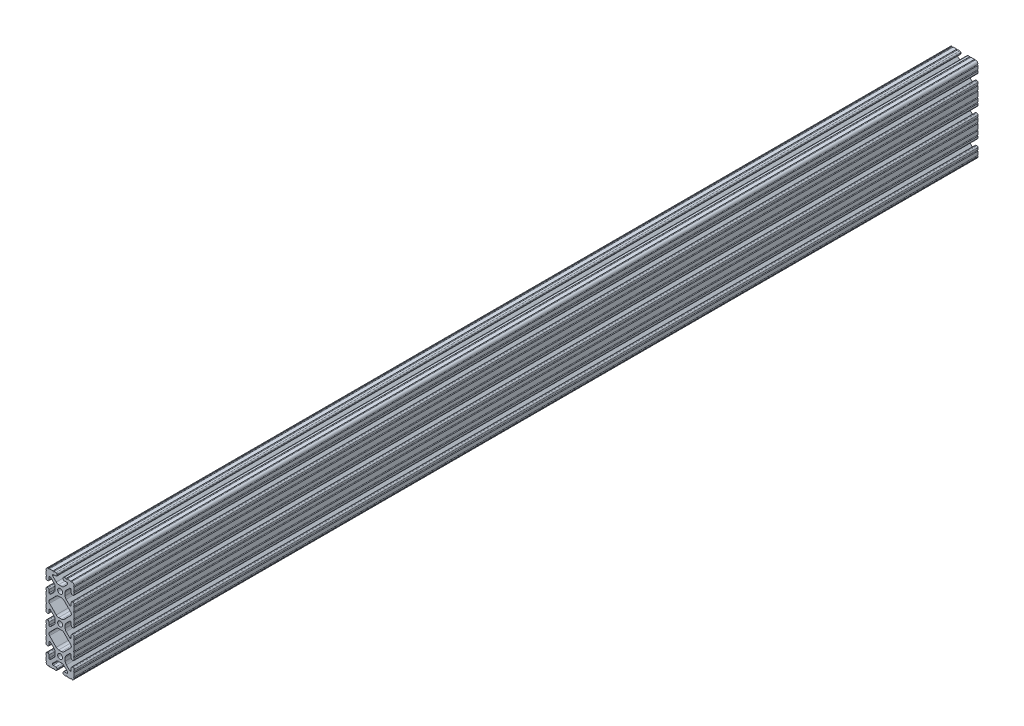
from build123d import *

# Parameters (mm, degrees)
SKETCH3_R                = 3.3274
BOSS_EXTRUDE1_DEPTH      = 609.6
BOSS_EXTRUDE1_DEPTH_BACK = 609.6


with BuildPart() as part:
    # Sketch3 → Boss-Extrude1 (new body, two sides)
    with BuildSketch(Plane.XY) as boss_extrude1_sk:
        with BuildLine():
            Line((-19.05, -5.6388), (-19.05, -8.023791585))
            ThreePointArc((-19.05, -8.023791585), (-18.288, -8.785791585), (-19.05, -9.547791585))
            Line((-19.05, -9.547791585), (-19.05, -13.984497194))
            ThreePointArc((-19.05, -13.984497194), (-18.288000009, -14.746497184), (-19.05, -15.508497175))
            Line((-19.05, -15.508497175), (-19.05, -22.30100558))
            ThreePointArc((-19.05, -22.30100558), (-18.288, -23.06300558), (-19.05, -23.82500558))
            Line((-19.05, -23.82500558), (-19.05, -28.653420271))
            ThreePointArc((-19.05, -28.653420271), (-18.288, -29.415420271), (-19.05, -30.177420271))
            Line((-19.05, -30.177420271), (-19.05, -32.4612))
            ThreePointArc((-19.05, -32.4612), (-18.588751759, -33.574751759), (-17.4752, -34.036))
            Line((-17.4752, -34.036), (-16.5608, -34.036))
            ThreePointArc((-16.5608, -34.036), (-15.447248241, -33.574751759), (-14.986, -32.4612))
            Line((-14.986, -32.4612), (-14.986, -28.7208616))
            ThreePointArc((-14.986, -28.7208616), (-14.725617928, -28.092243671), (-14.097, -27.8318616))
            Line((-14.097, -27.8318616), (-13.547779415, -27.8318616))
            ThreePointArc((-13.547779415, -27.8318616), (-13.207573844, -27.899532695), (-12.919161487, -28.092243671))
            Line((-12.919161487, -28.092243671), (-8.147584211, -32.863820948))
            ThreePointArc((-8.147584211, -32.863820948), (-7.117956996, -34.40476697), (-6.7564, -36.222436737))
            Line((-6.7564, -36.222436737), (-6.7564, -40.243886463))
            ThreePointArc((-6.7564, -40.243886463), (-7.222930328, -42.088789954), (-8.376184211, -43.602502252))
            Line((-8.376184211, -43.602502252), (-12.919161487, -48.145479528))
            ThreePointArc((-12.919161487, -48.145479528), (-13.207573844, -48.338190504), (-13.547779415, -48.4058616))
            Line((-13.547779415, -48.4058616), (-14.097, -48.4058616))
            ThreePointArc((-14.097, -48.4058616), (-14.725617928, -48.145479528), (-14.986, -47.5168616))
            Line((-14.986, -47.5168616), (-14.986, -43.7388))
            ThreePointArc((-14.986, -43.7388), (-15.447248241, -42.625248241), (-16.5608, -42.164))
            Line((-16.5608, -42.164), (-17.4752, -42.164))
            ThreePointArc((-17.4752, -42.164), (-18.588751759, -42.625248241), (-19.05, -43.7388))
            Line((-19.05, -43.7388), (-19.05, -46.125701672))
            ThreePointArc((-19.05, -46.125701672), (-18.288, -46.887701672), (-19.05, -47.649701672))
            Line((-19.05, -47.649701672), (-19.05, -52.476140467))
            ThreePointArc((-19.05, -52.476140467), (-18.2879999, -53.201256979), (-19.049898195, -53.92648046))
            ThreePointArc((-19.049898195, -53.92648046), (-18.099426561, -56.199426561), (-15.82648046, -57.149898195))
            ThreePointArc((-15.82648046, -57.149898195), (-15.101256979, -56.3879999), (-14.376140467, -57.15))
            Line((-14.376140467, -57.15), (-9.549701672, -57.15))
            ThreePointArc((-9.549701672, -57.15), (-8.787701672, -56.388), (-8.025701672, -57.15))
            Line((-8.025701672, -57.15), (-5.6388, -57.15))
            ThreePointArc((-5.6388, -57.15), (-4.525248241, -56.688751759), (-4.064, -55.5752))
            Line((-4.064, -55.5752), (-4.064, -54.6608))
            ThreePointArc((-4.064, -54.6608), (-4.525248241, -53.547248241), (-5.6388, -53.086))
            Line((-5.6388, -53.086), (-9.4168616, -53.086))
            ThreePointArc((-9.4168616, -53.086), (-10.032142363, -52.831142363), (-10.287, -52.2158616))
            Line((-10.287, -52.2158616), (-10.287, -51.628917816))
            ThreePointArc((-10.287, -51.628917816), (-10.219328904, -51.288712244), (-10.026617928, -51.000299887))
            Line((-10.026617928, -51.000299887), (-5.273902252, -46.247584211))
            ThreePointArc((-5.273902252, -46.247584211), (-3.73295623, -45.217956996), (-1.915286463, -44.8564))
            Line((-1.915286463, -44.8564), (1.915286463, -44.8564))
            ThreePointArc((1.915286463, -44.8564), (3.73295623, -45.217956996), (5.273902252, -46.247584211))
            Line((5.273902252, -46.247584211), (10.026617928, -51.000299887))
            ThreePointArc((10.026617928, -51.000299887), (10.219328904, -51.288712244), (10.287, -51.628917816))
            Line((10.287, -51.628917816), (10.287, -52.2158616))
            ThreePointArc((10.287, -52.2158616), (10.032142363, -52.831142363), (9.4168616, -53.086))
            Line((9.4168616, -53.086), (5.6388, -53.086))
            ThreePointArc((5.6388, -53.086), (4.525248241, -53.547248241), (4.064, -54.6608))
            Line((4.064, -54.6608), (4.064, -55.5752))
            ThreePointArc((4.064, -55.5752), (4.525248241, -56.688751759), (5.6388, -57.15))
            Line((5.6388, -57.15), (8.025701672, -57.15))
            ThreePointArc((8.025701672, -57.15), (8.787701672, -56.388), (9.549701672, -57.15))
            Line((9.549701672, -57.15), (14.376140467, -57.15))
            ThreePointArc((14.376140467, -57.15), (15.101256979, -56.3879999), (15.82648046, -57.149898195))
            ThreePointArc((15.82648046, -57.149898195), (18.099426561, -56.199426561), (19.049898195, -53.92648046))
            ThreePointArc((19.049898195, -53.92648046), (18.2879999, -53.201256979), (19.05, -52.476140467))
            Line((19.05, -52.476140467), (19.05, -47.649701672))
            ThreePointArc((19.05, -47.649701672), (18.288, -46.887701672), (19.05, -46.125701672))
            Line((19.05, -46.125701672), (19.05, -43.7388))
            ThreePointArc((19.05, -43.7388), (18.588751759, -42.625248241), (17.4752, -42.164))
            Line((17.4752, -42.164), (16.5608, -42.164))
            ThreePointArc((16.5608, -42.164), (15.447248241, -42.625248241), (14.986, -43.7388))
            Line((14.986, -43.7388), (14.986, -47.5168616))
            ThreePointArc((14.986, -47.5168616), (14.725617928, -48.145479528), (14.097, -48.4058616))
            Line((14.097, -48.4058616), (13.547779415, -48.4058616))
            ThreePointArc((13.547779415, -48.4058616), (13.207573844, -48.338190504), (12.919161487, -48.145479528))
            Line((12.919161487, -48.145479528), (8.376184211, -43.602502252))
            ThreePointArc((8.376184211, -43.602502252), (7.222930328, -42.088789954), (6.7564, -40.243886463))
            Line((6.7564, -40.243886463), (6.7564, -36.222436737))
            ThreePointArc((6.7564, -36.222436737), (7.117956996, -34.40476697), (8.147584211, -32.863820948))
            Line((8.147584211, -32.863820948), (12.919161487, -28.092243671))
            ThreePointArc((12.919161487, -28.092243671), (13.207573844, -27.899532695), (13.547779415, -27.8318616))
            Line((13.547779415, -27.8318616), (14.097, -27.8318616))
            ThreePointArc((14.097, -27.8318616), (14.725617928, -28.092243671), (14.986, -28.7208616))
            Line((14.986, -28.7208616), (14.986, -32.4612))
            ThreePointArc((14.986, -32.4612), (15.447248241, -33.574751759), (16.5608, -34.036))
            Line((16.5608, -34.036), (17.4752, -34.036))
            ThreePointArc((17.4752, -34.036), (18.588751759, -33.574751759), (19.05, -32.4612))
            Line((19.05, -32.4612), (19.05, -30.177420271))
            ThreePointArc((19.05, -30.177420271), (18.288, -29.415420271), (19.05, -28.653420271))
            Line((19.05, -28.653420271), (19.05, -23.82500558))
            ThreePointArc((19.05, -23.82500558), (18.288, -23.06300558), (19.05, -22.30100558))
            Line((19.05, -22.30100558), (19.05, -15.508497175))
            ThreePointArc((19.05, -15.508497175), (18.288000009, -14.746497184), (19.05, -13.984497194))
            Line((19.05, -13.984497194), (19.05, -9.547791585))
            ThreePointArc((19.05, -9.547791585), (18.288, -8.785791585), (19.05, -8.023791585))
            Line((19.05, -8.023791585), (19.05, -5.6388))
            ThreePointArc((19.05, -5.6388), (18.588751759, -4.525248241), (17.4752, -4.064))
            Line((17.4752, -4.064), (16.5608, -4.064))
            ThreePointArc((16.5608, -4.064), (15.447248241, -4.525248241), (14.986, -5.6388))
            Line((14.986, -5.6388), (14.986, -9.130462054))
            ThreePointArc((14.986, -9.130462054), (14.725617928, -9.759079983), (14.097, -10.019462054))
            Line((14.097, -10.019462054), (13.589600315, -10.019462054))
            ThreePointArc((13.589600315, -10.019462054), (13.249394744, -9.951790959), (12.960982387, -9.759079983))
            Line((12.960982387, -9.759079983), (8.147584211, -4.945681807))
            ThreePointArc((8.147584211, -4.945681807), (7.117956996, -3.404735785), (6.7564, -1.587066018))
            Line((6.7564, -1.587066018), (6.7564, 1.587066018))
            ThreePointArc((6.7564, 1.587066018), (7.117956996, 3.404735785), (8.147584211, 4.945681807))
            Line((8.147584211, 4.945681807), (12.960982387, 9.759079983))
            ThreePointArc((12.960982387, 9.759079983), (13.249394744, 9.951790959), (13.589600315, 10.019462054))
            Line((13.589600315, 10.019462054), (14.097, 10.019462054))
            ThreePointArc((14.097, 10.019462054), (14.725617928, 9.759079983), (14.986, 9.130462054))
            Line((14.986, 9.130462054), (14.986, 5.6388))
            ThreePointArc((14.986, 5.6388), (15.447248241, 4.525248241), (16.5608, 4.064))
            Line((16.5608, 4.064), (17.4752, 4.064))
            ThreePointArc((17.4752, 4.064), (18.588751759, 4.525248241), (19.05, 5.6388))
            Line((19.05, 5.6388), (19.05, 8.023791585))
            ThreePointArc((19.05, 8.023791585), (18.288, 8.785791585), (19.05, 9.547791585))
            Line((19.05, 9.547791585), (19.05, 13.984497194))
            ThreePointArc((19.05, 13.984497194), (18.288000009, 14.746497184), (19.05, 15.508497175))
            Line((19.05, 15.508497175), (19.05, 22.30100558))
            ThreePointArc((19.05, 22.30100558), (18.288, 23.06300558), (19.05, 23.82500558))
            Line((19.05, 23.82500558), (19.05, 28.653420271))
            ThreePointArc((19.05, 28.653420271), (18.288, 29.415420271), (19.05, 30.177420271))
            Line((19.05, 30.177420271), (19.05, 32.4612))
            ThreePointArc((19.05, 32.4612), (18.588751759, 33.574751759), (17.4752, 34.036))
            Line((17.4752, 34.036), (16.5608, 34.036))
            ThreePointArc((16.5608, 34.036), (15.447248241, 33.574751759), (14.986, 32.4612))
            Line((14.986, 32.4612), (14.986, 28.7208616))
            ThreePointArc((14.986, 28.7208616), (14.725617928, 28.092243671), (14.097, 27.8318616))
            Line((14.097, 27.8318616), (13.547779415, 27.8318616))
            ThreePointArc((13.547779415, 27.8318616), (13.207573844, 27.899532695), (12.919161487, 28.092243671))
            Line((12.919161487, 28.092243671), (8.147584211, 32.863820948))
            ThreePointArc((8.147584211, 32.863820948), (7.117956996, 34.40476697), (6.7564, 36.222436737))
            Line((6.7564, 36.222436737), (6.7564, 40.243886463))
            ThreePointArc((6.7564, 40.243886463), (7.222930328, 42.088789954), (8.376184211, 43.602502252))
            Line((8.376184211, 43.602502252), (12.919161487, 48.145479528))
            ThreePointArc((12.919161487, 48.145479528), (13.207573844, 48.338190504), (13.547779415, 48.4058616))
            Line((13.547779415, 48.4058616), (14.097, 48.4058616))
            ThreePointArc((14.097, 48.4058616), (14.725617928, 48.145479528), (14.986, 47.5168616))
            Line((14.986, 47.5168616), (14.986, 43.7388))
            ThreePointArc((14.986, 43.7388), (15.447248241, 42.625248241), (16.5608, 42.164))
            Line((16.5608, 42.164), (17.4752, 42.164))
            ThreePointArc((17.4752, 42.164), (18.588751759, 42.625248241), (19.05, 43.7388))
            Line((19.05, 43.7388), (19.05, 46.125701672))
            ThreePointArc((19.05, 46.125701672), (18.288, 46.887701672), (19.05, 47.649701672))
            Line((19.05, 47.649701672), (19.05, 52.476140467))
            ThreePointArc((19.05, 52.476140467), (18.2879999, 53.201256979), (19.049898195, 53.92648046))
            ThreePointArc((19.049898195, 53.92648046), (18.099426561, 56.199426561), (15.82648046, 57.149898195))
            ThreePointArc((15.82648046, 57.149898195), (15.101256979, 56.3879999), (14.376140467, 57.15))
            Line((14.376140467, 57.15), (9.549701672, 57.15))
            ThreePointArc((9.549701672, 57.15), (8.787701672, 56.388), (8.025701672, 57.15))
            Line((8.025701672, 57.15), (5.6388, 57.15))
            ThreePointArc((5.6388, 57.15), (4.525248241, 56.688751759), (4.064, 55.5752))
            Line((4.064, 55.5752), (4.064, 54.6608))
            ThreePointArc((4.064, 54.6608), (4.525248241, 53.547248241), (5.6388, 53.086))
            Line((5.6388, 53.086), (9.4168616, 53.086))
            ThreePointArc((9.4168616, 53.086), (10.032142363, 52.831142363), (10.287, 52.2158616))
            Line((10.287, 52.2158616), (10.287, 51.628917816))
            ThreePointArc((10.287, 51.628917816), (10.219328904, 51.288712244), (10.026617928, 51.000299887))
            Line((10.026617928, 51.000299887), (5.273902252, 46.247584211))
            ThreePointArc((5.273902252, 46.247584211), (3.73295623, 45.217956996), (1.915286463, 44.8564))
            Line((1.915286463, 44.8564), (-1.915286463, 44.8564))
            ThreePointArc((-1.915286463, 44.8564), (-3.73295623, 45.217956996), (-5.273902252, 46.247584211))
            Line((-5.273902252, 46.247584211), (-10.026617928, 51.000299887))
            ThreePointArc((-10.026617928, 51.000299887), (-10.219328904, 51.288712244), (-10.287, 51.628917816))
            Line((-10.287, 51.628917816), (-10.287, 52.2158616))
            ThreePointArc((-10.287, 52.2158616), (-10.032142363, 52.831142363), (-9.4168616, 53.086))
            Line((-9.4168616, 53.086), (-5.6388, 53.086))
            ThreePointArc((-5.6388, 53.086), (-4.525248241, 53.547248241), (-4.064, 54.6608))
            Line((-4.064, 54.6608), (-4.064, 55.5752))
            ThreePointArc((-4.064, 55.5752), (-4.525248241, 56.688751759), (-5.6388, 57.15))
            Line((-5.6388, 57.15), (-8.025701672, 57.15))
            ThreePointArc((-8.025701672, 57.15), (-8.787701672, 56.388), (-9.549701672, 57.15))
            Line((-9.549701672, 57.15), (-14.376140467, 57.15))
            ThreePointArc((-14.376140467, 57.15), (-15.101256979, 56.3879999), (-15.82648046, 57.149898195))
            ThreePointArc((-15.82648046, 57.149898195), (-18.099426561, 56.199426561), (-19.049898195, 53.92648046))
            ThreePointArc((-19.049898195, 53.92648046), (-18.2879999, 53.201256979), (-19.05, 52.476140467))
            Line((-19.05, 52.476140467), (-19.05, 47.649701672))
            ThreePointArc((-19.05, 47.649701672), (-18.288, 46.887701672), (-19.05, 46.125701672))
            Line((-19.05, 46.125701672), (-19.05, 43.7388))
            ThreePointArc((-19.05, 43.7388), (-18.588751759, 42.625248241), (-17.4752, 42.164))
            Line((-17.4752, 42.164), (-16.5608, 42.164))
            ThreePointArc((-16.5608, 42.164), (-15.447248241, 42.625248241), (-14.986, 43.7388))
            Line((-14.986, 43.7388), (-14.986, 47.5168616))
            ThreePointArc((-14.986, 47.5168616), (-14.725617928, 48.145479528), (-14.097, 48.4058616))
            Line((-14.097, 48.4058616), (-13.547779415, 48.4058616))
            ThreePointArc((-13.547779415, 48.4058616), (-13.207573844, 48.338190504), (-12.919161487, 48.145479528))
            Line((-12.919161487, 48.145479528), (-8.376184211, 43.602502252))
            ThreePointArc((-8.376184211, 43.602502252), (-7.222930328, 42.088789954), (-6.7564, 40.243886463))
            Line((-6.7564, 40.243886463), (-6.7564, 36.222436737))
            ThreePointArc((-6.7564, 36.222436737), (-7.117956996, 34.40476697), (-8.147584211, 32.863820948))
            Line((-8.147584211, 32.863820948), (-12.919161487, 28.092243671))
            ThreePointArc((-12.919161487, 28.092243671), (-13.207573844, 27.899532695), (-13.547779415, 27.8318616))
            Line((-13.547779415, 27.8318616), (-14.097, 27.8318616))
            ThreePointArc((-14.097, 27.8318616), (-14.725617928, 28.092243671), (-14.986, 28.7208616))
            Line((-14.986, 28.7208616), (-14.986, 32.4612))
            ThreePointArc((-14.986, 32.4612), (-15.447248241, 33.574751759), (-16.5608, 34.036))
            Line((-16.5608, 34.036), (-17.4752, 34.036))
            ThreePointArc((-17.4752, 34.036), (-18.588751759, 33.574751759), (-19.05, 32.4612))
            Line((-19.05, 32.4612), (-19.05, 30.177420271))
            ThreePointArc((-19.05, 30.177420271), (-18.288, 29.415420271), (-19.05, 28.653420271))
            Line((-19.05, 28.653420271), (-19.05, 23.82500558))
            ThreePointArc((-19.05, 23.82500558), (-18.288, 23.06300558), (-19.05, 22.30100558))
            Line((-19.05, 22.30100558), (-19.05, 15.508497175))
            ThreePointArc((-19.05, 15.508497175), (-18.288000009, 14.746497184), (-19.05, 13.984497194))
            Line((-19.05, 13.984497194), (-19.05, 9.547791585))
            ThreePointArc((-19.05, 9.547791585), (-18.288, 8.785791585), (-19.05, 8.023791585))
            Line((-19.05, 8.023791585), (-19.05, 5.6388))
            ThreePointArc((-19.05, 5.6388), (-18.588751759, 4.525248241), (-17.4752, 4.064))
            Line((-17.4752, 4.064), (-16.5608, 4.064))
            ThreePointArc((-16.5608, 4.064), (-15.447248241, 4.525248241), (-14.986, 5.6388))
            Line((-14.986, 5.6388), (-14.986, 9.130462054))
            ThreePointArc((-14.986, 9.130462054), (-14.725617928, 9.759079983), (-14.097, 10.019462054))
            Line((-14.097, 10.019462054), (-13.589600315, 10.019462054))
            ThreePointArc((-13.589600315, 10.019462054), (-13.249394744, 9.951790959), (-12.960982387, 9.759079983))
            Line((-12.960982387, 9.759079983), (-8.147584211, 4.945681807))
            ThreePointArc((-8.147584211, 4.945681807), (-7.117956996, 3.404735785), (-6.7564, 1.587066018))
            Line((-6.7564, 1.587066018), (-6.7564, -1.587066018))
            ThreePointArc((-6.7564, -1.587066018), (-7.117956996, -3.404735785), (-8.147584211, -4.945681807))
            Line((-8.147584211, -4.945681807), (-12.960982387, -9.759079983))
            ThreePointArc((-12.960982387, -9.759079983), (-13.249394744, -9.951790959), (-13.589600315, -10.019462054))
            Line((-13.589600315, -10.019462054), (-14.097, -10.019462054))
            ThreePointArc((-14.097, -10.019462054), (-14.725617928, -9.759079983), (-14.986, -9.130462054))
            Line((-14.986, -9.130462054), (-14.986, -5.6388))
            ThreePointArc((-14.986, -5.6388), (-15.447248241, -4.525248241), (-16.5608, -4.064))
            Line((-16.5608, -4.064), (-17.4752, -4.064))
            ThreePointArc((-17.4752, -4.064), (-18.588751759, -4.525248241), (-19.05, -5.6388))
        make_face()
        with Locations((0, 38.1)):
            Circle(SKETCH3_R, mode=Mode.SUBTRACT)
        Circle(SKETCH3_R, mode=Mode.SUBTRACT)
        with Locations((0, -38.1)):
            Circle(SKETCH3_R, mode=Mode.SUBTRACT)
        with BuildLine():
            Line((14.281465557, 20.982575684), (5.292763852, 29.971277389))
            ThreePointArc((5.292763852, 29.971277389), (3.75181783, 31.000904603), (1.934148062, 31.3624616))
            Line((1.934148062, 31.3624616), (-1.934148062, 31.3624616))
            ThreePointArc((-1.934148062, 31.3624616), (-3.75181783, 31.000904603), (-5.292763852, 29.971277389))
            Line((-5.292763852, 29.971277389), (-14.281465557, 20.982575684))
            ThreePointArc((-14.281465557, 20.982575684), (-15.142128565, 18.904751377), (-14.281465557, 16.82692707))
            Line((-14.281465557, 16.82692707), (-5.292763852, 7.838225365))
            ThreePointArc((-5.292763852, 7.838225365), (-3.75181783, 6.808598151), (-1.934148062, 6.447041155))
            Line((-1.934148062, 6.447041155), (1.934148062, 6.447041155))
            ThreePointArc((1.934148062, 6.447041155), (3.75181783, 6.808598151), (5.292763852, 7.838225365))
            Line((5.292763852, 7.838225365), (14.281465557, 16.82692707))
            ThreePointArc((14.281465557, 16.82692707), (15.142128565, 18.904751377), (14.281465557, 20.982575684))
        make_face(mode=Mode.SUBTRACT)
        with BuildLine():
            Line((-14.281465557, -20.982575684), (-5.292763852, -29.971277389))
            ThreePointArc((-5.292763852, -29.971277389), (-3.75181783, -31.000904603), (-1.934148062, -31.3624616))
            Line((-1.934148062, -31.3624616), (1.934148062, -31.3624616))
            ThreePointArc((1.934148062, -31.3624616), (3.75181783, -31.000904603), (5.292763852, -29.971277389))
            Line((5.292763852, -29.971277389), (14.281465557, -20.982575684))
            ThreePointArc((14.281465557, -20.982575684), (15.142128565, -18.904751377), (14.281465557, -16.82692707))
            Line((14.281465557, -16.82692707), (5.292763852, -7.838225365))
            ThreePointArc((5.292763852, -7.838225365), (3.75181783, -6.808598151), (1.934148062, -6.447041155))
            Line((1.934148062, -6.447041155), (-1.934148062, -6.447041155))
            ThreePointArc((-1.934148062, -6.447041155), (-3.75181783, -6.808598151), (-5.292763852, -7.838225365))
            Line((-5.292763852, -7.838225365), (-14.281465557, -16.82692707))
            ThreePointArc((-14.281465557, -16.82692707), (-15.142128565, -18.904751377), (-14.281465557, -20.982575684))
        make_face(mode=Mode.SUBTRACT)
    extrude(amount=BOSS_EXTRUDE1_DEPTH)
    extrude(boss_extrude1_sk.sketch, amount=-BOSS_EXTRUDE1_DEPTH_BACK)


solid = part.part
